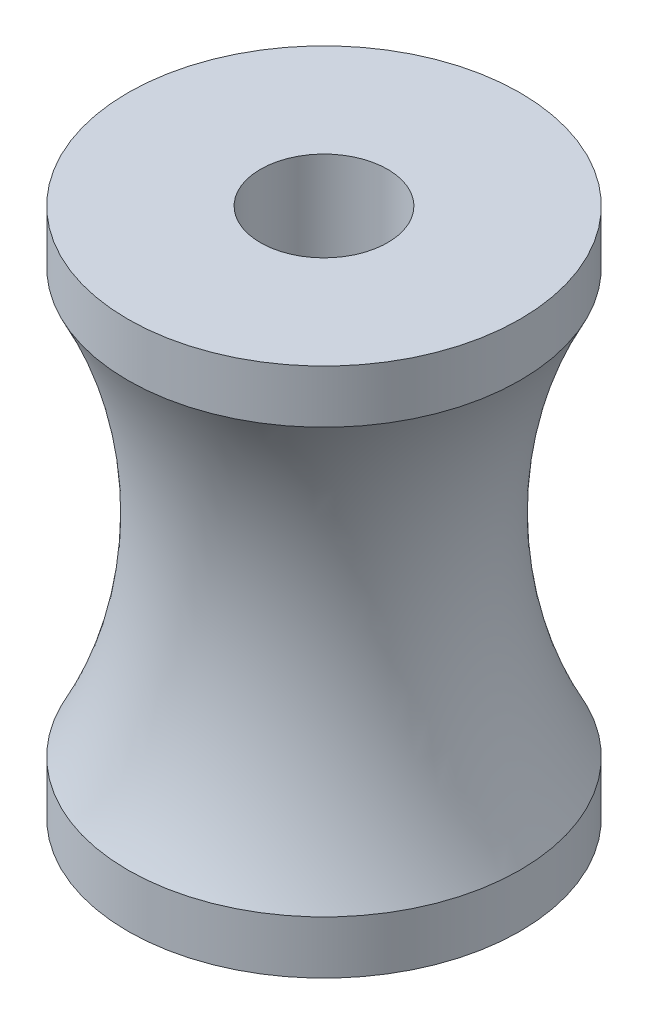
from build123d import *


with BuildPart() as part:
    # Sketch1 → Revolve1 (revolve)
    with BuildSketch(Plane.XY):
        with BuildLine():
            Line((-120, 500), (-370, 500))
            Line((-370, 500), (-370, 400))
            ThreePointArc((-370, 400), (-271.314652427, 0), (-370, -400))
            Line((-370, -400), (-370, -500))
            Line((-370, -500), (-120, -500))
            Line((-120, -500), (-120, 500))
        make_face()
    revolve(axis=Axis((0, 500, 0), (0, -1, 0)))


solid = part.part
